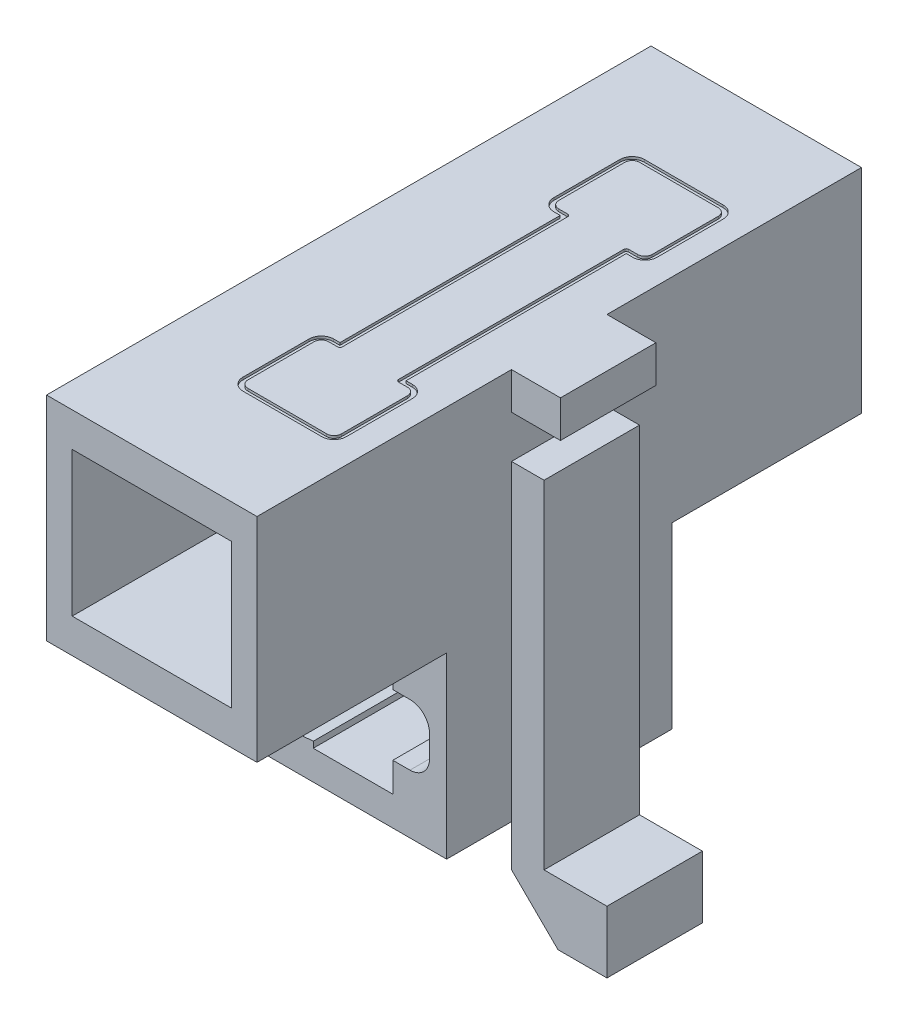
from build123d import *

# Parameters (mm, degrees)
SKETCH1_W                = 8.6
SKETCH1_H                = 8.7
SKETCH1_W_2              = 6.5
SKETCH1_H_2              = 5.9
BOSS_EXTRUDE1_DEPTH      = 24.7
SKETCH2_W                = 2
SKETCH2_H                = 1.51
BOSS_EXTRUDE2_DEPTH      = 1.95
BOSS_EXTRUDE2_DEPTH_BACK = 1.95
BOSS_EXTRUDE3_DEPTH      = 4.6
BOSS_EXTRUDE3_DEPTH_BACK = 4.6
CUT_EXTRUDE1_DEPTH       = 0.1


with BuildPart() as part:
    # Sketch1 → Boss-Extrude1 (new body)
    with BuildSketch(Plane.XY):
        Rectangle(SKETCH1_W, SKETCH1_H)
        Rectangle(SKETCH1_W_2, SKETCH1_H_2, mode=Mode.SUBTRACT)
    extrude(amount=BOSS_EXTRUDE1_DEPTH)

    # Sketch2 → Boss-Extrude2 (add, two sides)
    with BuildSketch(Plane.XY.offset(12.35)) as boss_extrude2_sk:
        with Locations((5.3, 3.595)):
            Rectangle(SKETCH2_W, SKETCH2_H)
        Polygon((4.3, 1.1), (5.63, 1.1), (5.63, -12.69), (8.2, -12.69), (8.2, -15.23), (6.2, -15.23), (4.3, -13.35), align=None)
    extrude(amount=BOSS_EXTRUDE2_DEPTH)
    extrude(boss_extrude2_sk.sketch, amount=-BOSS_EXTRUDE2_DEPTH_BACK)

    # Sketch3 → Boss-Extrude3 (add, two sides)
    with BuildSketch(Plane.XY.offset(12.35)) as boss_extrude3_sk:
        with BuildLine():
            Line((4.3, -4.35), (-4.3, -4.35))
            Line((-4.3, -4.35), (-4.3, -5.55))
            Line((-4.3, -5.55), (-1.15, -5.8))
            Line((-1.15, -5.8), (-1.15, -5.55))
            Line((-1.15, -5.55), (2.1, -5.55))
            Line((2.1, -5.55), (2.1, -6.75))
            Line((2.1, -6.75), (2.8, -6.75))
            ThreePointArc((2.8, -6.75), (3.365685425, -6.984314575), (3.6, -7.55))
            Line((3.6, -7.55), (3.6, -8.45))
            ThreePointArc((3.6, -8.45), (3.365685425, -9.015685425), (2.8, -9.25))
            Line((2.8, -9.25), (2.1, -9.25))
            Line((2.1, -9.25), (2.1, -10.45))
            Line((2.1, -10.45), (-1.15, -10.45))
            Line((-1.15, -10.45), (-1.15, -10.2))
            Line((-1.15, -10.2), (-4.3, -10.45))
            Line((-4.3, -10.45), (-4.3, -11.65))
            Line((-4.3, -11.65), (4.3, -11.65))
            Line((4.3, -11.65), (4.3, -4.35))
        make_face()
    extrude(amount=BOSS_EXTRUDE3_DEPTH)
    extrude(boss_extrude3_sk.sketch, amount=-BOSS_EXTRUDE3_DEPTH_BACK)

    # Sketch4 → Cut-Extrude1 (cut)
    with BuildSketch(Plane(origin=(0, 4.35, 0), x_dir=(1, 0, 0), z_dir=(0, 1, 0))):
        with BuildLine():
            Line((-0.16, -12.35), (-0.16, -16.85))
            Line((-0.16, -16.85), (-0.42, -16.85))
            ThreePointArc((-0.42, -16.85), (-0.773553391, -16.996446609), (-0.92, -17.35))
            Line((-0.92, -17.35), (-0.92, -20.05))
            ThreePointArc((-0.92, -20.05), (-0.773553391, -20.403553391), (-0.42, -20.55))
            Line((-0.42, -20.55), (2.8, -20.55))
            ThreePointArc((2.8, -20.55), (3.153553391, -20.403553391), (3.3, -20.05))
            Line((3.3, -20.05), (3.3, -17.35))
            ThreePointArc((3.3, -17.35), (3.153553391, -16.996446609), (2.8, -16.85))
            Line((2.8, -16.85), (2.54, -16.85))
            Line((2.54, -16.85), (2.54, -12.35))
            Line((2.54, -12.35), (2.54, -7.85))
            Line((2.54, -7.85), (2.8, -7.85))
            ThreePointArc((2.8, -7.85), (3.153553391, -7.703553391), (3.3, -7.35))
            Line((3.3, -7.35), (3.3, -4.65))
            ThreePointArc((3.3, -4.65), (3.153553391, -4.296446609), (2.8, -4.15))
            Line((2.8, -4.15), (-0.42, -4.15))
            ThreePointArc((-0.42, -4.15), (-0.773553391, -4.296446609), (-0.92, -4.65))
            Line((-0.92, -4.65), (-0.92, -7.35))
            ThreePointArc((-0.92, -7.35), (-0.773553391, -7.703553391), (-0.42, -7.85))
            Line((-0.42, -7.85), (-0.16, -7.85))
            Line((-0.16, -7.85), (-0.16, -12.35))
        make_face()
        with BuildLine():
            Line((2.34, -16.95), (2.34, -7.75))
            ThreePointArc((2.34, -7.75), (2.369289322, -7.679289322), (2.44, -7.65))
            Line((2.44, -7.65), (2.8, -7.65))
            ThreePointArc((2.8, -7.65), (3.012132034, -7.562132034), (3.1, -7.35))
            Line((3.1, -7.35), (3.1, -4.65))
            ThreePointArc((3.1, -4.65), (3.012132034, -4.437867966), (2.8, -4.35))
            Line((2.8, -4.35), (-0.42, -4.35))
            ThreePointArc((-0.42, -4.35), (-0.632132034, -4.437867966), (-0.72, -4.65))
            Line((-0.72, -4.65), (-0.72, -7.35))
            ThreePointArc((-0.72, -7.35), (-0.632132034, -7.562132034), (-0.42, -7.65))
            Line((-0.42, -7.65), (-0.06, -7.65))
            ThreePointArc((-0.06, -7.65), (0.010710678, -7.679289322), (0.04, -7.75))
            Line((0.04, -7.75), (0.04, -16.95))
            ThreePointArc((0.04, -16.95), (0.010710678, -17.020710678), (-0.06, -17.05))
            Line((-0.06, -17.05), (-0.42, -17.05))
            ThreePointArc((-0.42, -17.05), (-0.632132034, -17.137867966), (-0.72, -17.35))
            Line((-0.72, -17.35), (-0.72, -20.05))
            ThreePointArc((-0.72, -20.05), (-0.632132034, -20.262132034), (-0.42, -20.35))
            Line((-0.42, -20.35), (2.8, -20.35))
            ThreePointArc((2.8, -20.35), (3.012132034, -20.262132034), (3.1, -20.05))
            Line((3.1, -20.05), (3.1, -17.35))
            ThreePointArc((3.1, -17.35), (3.012132034, -17.137867966), (2.8, -17.05))
            Line((2.8, -17.05), (2.44, -17.05))
            ThreePointArc((2.44, -17.05), (2.369289322, -17.020710678), (2.34, -16.95))
        make_face(mode=Mode.SUBTRACT)
    extrude(amount=-CUT_EXTRUDE1_DEPTH, mode=Mode.SUBTRACT)


solid = part.part
